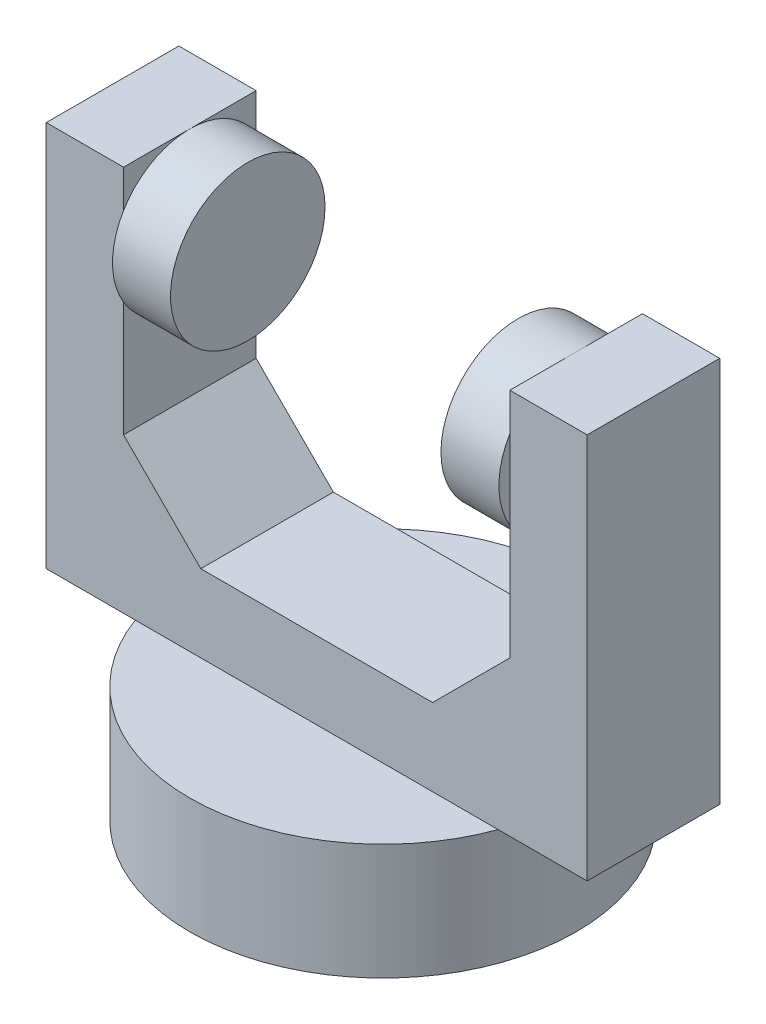
from build123d import *

# Parameters (mm, degrees)
SKETCH1_R           = 12.5
BOSS_EXTRUDE1_DEPTH = 7.5
SKETCH2_W           = 35
SKETCH2_H           = 8.580767914
BOSS_EXTRUDE2_DEPTH = 25
SKETCH3_W           = 25
SKETCH3_H           = 8.580767914
CUT_EXTRUDE1_DEPTH  = 20
SKETCH4_R           = 5
BOSS_EXTRUDE3_DEPTH = 3.75
SKETCH5_R           = 5
BOSS_EXTRUDE4_DEPTH = 3.75
CHAMFER1_SIZE       = 5
CHAMFER2_SIZE       = 5


with BuildPart() as part:
    # Sketch1 → Boss-Extrude1 (new body)
    with BuildSketch(Plane(origin=(0, 0, 0), x_dir=(1, 0, 0), z_dir=(0, 1, 0))):
        Circle(SKETCH1_R)
    extrude(amount=BOSS_EXTRUDE1_DEPTH)

    # Sketch2 → Boss-Extrude2 (add)
    with BuildSketch(Plane(origin=(0, 7.5, 0), x_dir=(1, 0, 0), z_dir=(0, 1, 0))):
        Rectangle(SKETCH2_W, SKETCH2_H)
    extrude(amount=BOSS_EXTRUDE2_DEPTH)

    # Sketch3 → Cut-Extrude1 (cut)
    with BuildSketch(Plane(origin=(0, 32.5, 0), x_dir=(1, 0, 0), z_dir=(0, 1, 0))):
        Rectangle(SKETCH3_W, SKETCH3_H)
    extrude(amount=-CUT_EXTRUDE1_DEPTH, mode=Mode.SUBTRACT)

    # Sketch4 → Boss-Extrude3 (add)
    with BuildSketch(Plane(origin=(-12.5, 0, 0), x_dir=(0, 0, -1), z_dir=(1, 0, 0))):
        with Locations((0, 27.5)):
            Circle(SKETCH4_R)
    extrude(amount=BOSS_EXTRUDE3_DEPTH)

    # Sketch5 → Boss-Extrude4 (add)
    with BuildSketch(Plane.ZY.offset(-12.5)):
        with Locations((0, 27.5)):
            Circle(SKETCH5_R)
    extrude(amount=BOSS_EXTRUDE4_DEPTH)

    # Chamfer1
    chamfer1_edges = [part.edges().sort_by_distance(p)[0] for p in [
        (-12.5, 12.5, 0),
    ]]
    chamfer(chamfer1_edges, length=CHAMFER1_SIZE)

    # Chamfer2
    chamfer2_edges = [part.edges().sort_by_distance(p)[0] for p in [
        (12.5, 12.5, 0),
    ]]
    chamfer(chamfer2_edges, length=CHAMFER2_SIZE)


solid = part.part
